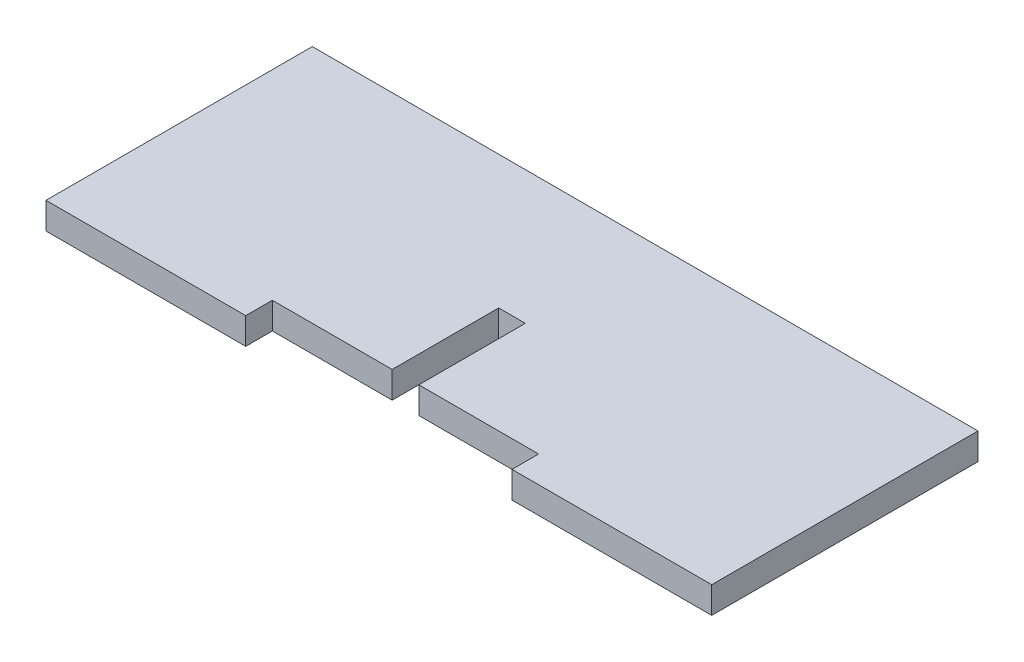
from build123d import *

# Parameters (mm, degrees)
RESSALTO_EXTRUS_O1_DEPTH = 3
ESBO_O2_W                = 30
ESBO_O2_H                = 16.142769795
CORTE_EXTRUS_O2_DEPTH    = 3


with BuildPart() as part:
    # Esboço1 → Ressalto-extrusão1 (new body)
    with BuildSketch(Plane(origin=(0, 0, 0), x_dir=(1, 0, 0), z_dir=(0, 1, 0))):
        Polygon((36, 7.331730769), (-39, 7.331730769), (-39, -22.668269231), (-3, -22.668269231), (-3, -7.668269231), (0, -7.668269231), (0, -22.668269231), (36, -22.668269231), align=None)
    extrude(amount=RESSALTO_EXTRUS_O1_DEPTH)

    # Esboço2 → Corte-extrusão2 (cut)
    with BuildSketch(Plane.XY.offset(22.668269231)):
        with Locations((-1.5, 0.209360247)):
            Rectangle(ESBO_O2_W, ESBO_O2_H)
    extrude(amount=-CORTE_EXTRUS_O2_DEPTH, mode=Mode.SUBTRACT)


solid = part.part
